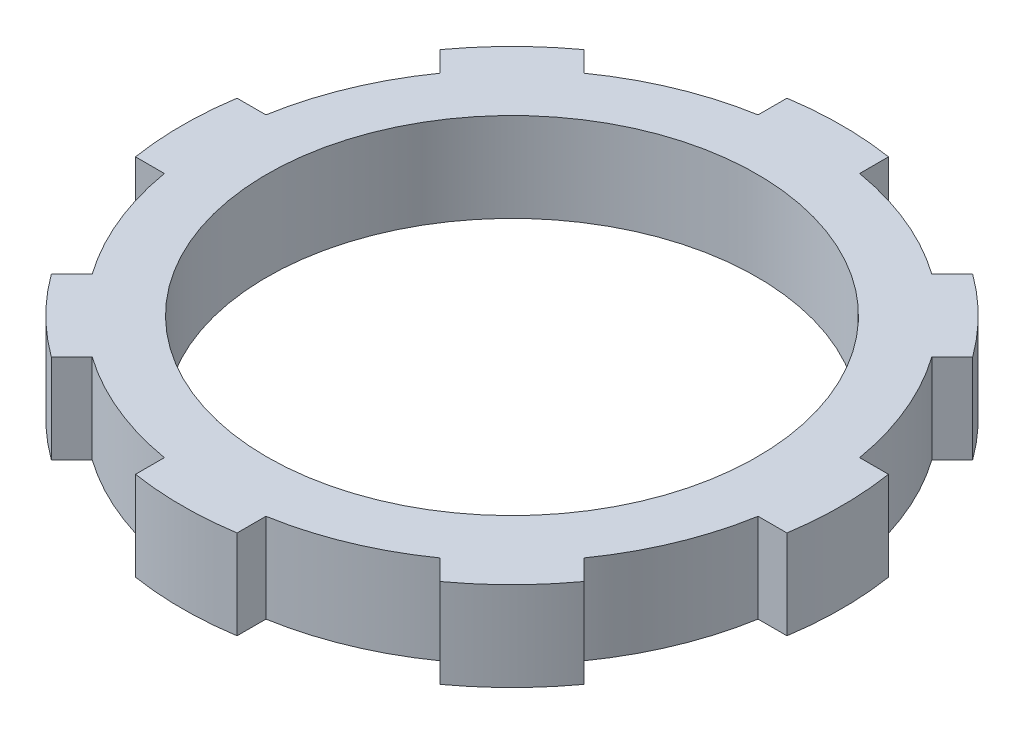
from build123d import *

# Parameters (mm, degrees)
SKETCH_2_R      = 13.75
EXTRUDE_1_DEPTH = 5


with BuildPart() as part:
    # Эскиз2 → Бобышка-Вытянуть1 (new body)
    with BuildSketch(Plane(origin=(0, 0, 0), x_dir=(1, 0, 0), z_dir=(0, 1, 0))):
        with BuildLine():
            Line((-2.85, 18.279154794), (-2.85, 16.657956057))
            ThreePointArc((-2.85, 16.657956057), (-6.467350007, 15.613564099), (-9.763699362, 13.794208015))
            Line((-9.763699362, 13.794208015), (-10.910059983, 14.940568636))
            ThreePointArc((-10.910059983, 14.940568636), (-13.081475452, 13.081475452), (-14.940568636, 10.910059983))
            Line((-14.940568636, 10.910059983), (-13.794208015, 9.763699362))
            ThreePointArc((-13.794208015, 9.763699362), (-15.613564099, 6.467350007), (-16.657956057, 2.85))
            Line((-16.657956057, 2.85), (-18.279154794, 2.85))
            ThreePointArc((-18.279154794, 2.85), (-18.5, 0), (-18.279154794, -2.85))
            Line((-18.279154794, -2.85), (-16.657956057, -2.85))
            ThreePointArc((-16.657956057, -2.85), (-15.613564099, -6.467350007), (-13.794208015, -9.763699362))
            Line((-13.794208015, -9.763699362), (-14.940568636, -10.910059983))
            ThreePointArc((-14.940568636, -10.910059983), (-13.081475452, -13.081475452), (-10.910059983, -14.940568636))
            Line((-10.910059983, -14.940568636), (-9.763699362, -13.794208015))
            ThreePointArc((-9.763699362, -13.794208015), (-6.467350007, -15.613564099), (-2.85, -16.657956057))
            Line((-2.85, -16.657956057), (-2.85, -18.279154794))
            ThreePointArc((-2.85, -18.279154794), (0, -18.5), (2.85, -18.279154794))
            Line((2.85, -18.279154794), (2.85, -16.657956057))
            ThreePointArc((2.85, -16.657956057), (6.467350007, -15.613564099), (9.763699362, -13.794208015))
            Line((9.763699362, -13.794208015), (10.910059983, -14.940568636))
            ThreePointArc((10.910059983, -14.940568636), (13.081475452, -13.081475452), (14.940568636, -10.910059983))
            Line((14.940568636, -10.910059983), (13.794208015, -9.763699362))
            ThreePointArc((13.794208015, -9.763699362), (15.613564099, -6.467350007), (16.657956057, -2.85))
            Line((16.657956057, -2.85), (18.279154794, -2.85))
            ThreePointArc((18.279154794, -2.85), (18.5, 0), (18.279154794, 2.85))
            Line((18.279154794, 2.85), (16.657956057, 2.85))
            ThreePointArc((16.657956057, 2.85), (15.613564099, 6.467350007), (13.794208015, 9.763699362))
            Line((13.794208015, 9.763699362), (14.940568636, 10.910059983))
            ThreePointArc((14.940568636, 10.910059983), (13.081475452, 13.081475452), (10.910059983, 14.940568636))
            Line((10.910059983, 14.940568636), (9.763699362, 13.794208015))
            ThreePointArc((9.763699362, 13.794208015), (6.467350007, 15.613564099), (2.85, 16.657956057))
            Line((2.85, 16.657956057), (2.85, 18.279154794))
            ThreePointArc((2.85, 18.279154794), (0, 18.5), (-2.85, 18.279154794))
        make_face()
        Circle(SKETCH_2_R, mode=Mode.SUBTRACT)
    extrude(amount=EXTRUDE_1_DEPTH)


solid = part.part
